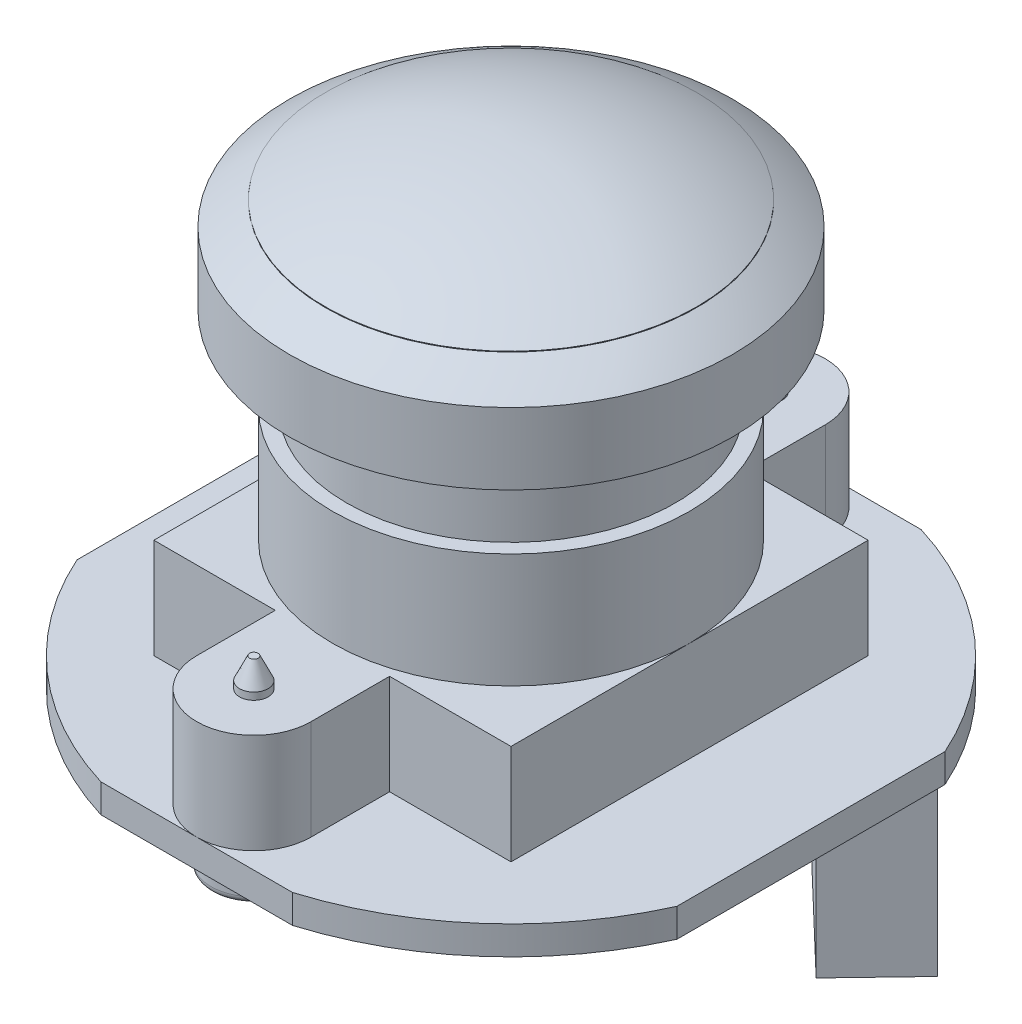
from build123d import *

# Parameters (mm, degrees)
BOSS_EXTRUDE1_DEPTH   = 1
BOSS_EXTRUDE2_DEPTH   = 6
SKETCH4_R             = 1.5
SKETCH4_W             = 6.5
SKETCH4_H             = 6.5
SKETCH4_W_2           = 3.913005348
SKETCH4_H_2           = 6.097566615
BOSS_EXTRUDE6_DEPTH   = 1
FILLET1_R             = 0.25
BOSS_EXTRUDE7_DEPTH   = 3.5
SKETCH6_R             = 6.25
BOSS_EXTRUDE8_DEPTH   = 4
SKETCH7_R             = 0.5
BOSS_EXTRUDE9_DEPTH   = 1
CHAMFER1_SIZE         = 0.75
CHAMFER1_SIZE2        = 0.349730744
CHAMFER1_PART_2_SIZE  = 0.75
CHAMFER1_PART_2_SIZE2 = 0.349730744


with BuildPart() as part:
    # Sketch1 → Boss-Extrude1 (new body)
    with BuildSketch(Plane(origin=(0, 0, 0), x_dir=(1, 0, 0), z_dir=(0, 1, 0))):
        with BuildLine():
            Line((-3.354101966, 11), (3.354101966, 11))
            ThreePointArc((3.354101966, 11), (7.611619318, 8.620513404), (10.5, 4.69041576))
            Line((10.5, 4.69041576), (10.5, -4.69041576))
            ThreePointArc((10.5, -4.69041576), (7.611619318, -8.620513404), (3.354101966, -11))
            Line((3.354101966, -11), (-3.354101966, -11))
            ThreePointArc((-3.354101966, -11), (-7.611619318, -8.620513404), (-10.5, -4.69041576))
            Line((-10.5, -4.69041576), (-10.5, 4.69041576))
            ThreePointArc((-10.5, 4.69041576), (-7.611619318, 8.620513404), (-3.354101966, 11))
        make_face()
    extrude(amount=BOSS_EXTRUDE1_DEPTH)

    # Sketch2 → Boss-Extrude2 (add)
    with BuildSketch(Plane.XZ):
        Polygon((8.109719748, -2.570195786), (10.184176938, -4.737366146), (4.405055978, -10.269251985), (2.330598788, -8.102081625), align=None)
    extrude(amount=BOSS_EXTRUDE2_DEPTH)

    # Sketch4 → Boss-Extrude6 (add)
    with BuildSketch(Plane.XZ):
        with Locations((0, -9)):
            Circle(SKETCH4_R)
        with Locations((0, 9)):
            Circle(SKETCH4_R)
        with Locations((1.885591241, -1.931388967)):
            Rectangle(SKETCH4_W, SKETCH4_H)
        Polygon((-6.789671936, 7.633587439), (-2.564617425, 4.781139469), (-5.233344576, 0.828212788), (-9.458399087, 3.680660758), align=None)
        with Locations((-6.013545028, -4.933267479)):
            Rectangle(SKETCH4_W_2, SKETCH4_H_2)
        with BuildLine():
            Line((7.537936682, 4.261094781), (8.522189561, 4.261094781))
            ThreePointArc((8.522189561, 4.261094781), (8.906288246, 3.876996096), (8.522189561, 3.492897412))
            Line((8.522189561, 3.492897412), (7.537936682, 3.492897412))
            ThreePointArc((7.537936682, 3.492897412), (7.153837998, 3.876996096), (7.537936682, 4.261094781))
        make_face()
        with BuildLine():
            Line((7.549939766, 3.276841902), (8.534192645, 3.276841902))
            ThreePointArc((8.534192645, 3.276841902), (8.918291329, 2.892743217), (8.534192645, 2.508644533))
            Line((8.534192645, 2.508644533), (7.549939766, 2.508644533))
            ThreePointArc((7.549939766, 2.508644533), (7.165841082, 2.892743217), (7.549939766, 3.276841902))
        make_face()
        with BuildLine():
            Line((7.393899676, 0.228058594), (8.378152554, 0.228058594))
            ThreePointArc((8.378152554, 0.228058594), (8.762251239, -0.156040091), (8.378152554, -0.540138775))
            Line((8.378152554, -0.540138775), (7.393899676, -0.540138775))
            ThreePointArc((7.393899676, -0.540138775), (7.009800991, -0.156040091), (7.393899676, 0.228058594))
        make_face()
        with BuildLine():
            Line((7.405902759, -0.756194285), (8.390155638, -0.756194285))
            ThreePointArc((8.390155638, -0.756194285), (8.774254323, -1.140292969), (8.390155638, -1.524391654))
            Line((8.390155638, -1.524391654), (7.405902759, -1.524391654))
            ThreePointArc((7.405902759, -1.524391654), (7.021804075, -1.140292969), (7.405902759, -0.756194285))
        make_face()
    extrude(amount=BOSS_EXTRUDE6_DEPTH)

    # Fillet1
    fillet1_edges = [part.edges().sort_by_distance(p)[0] for p in [
        (-1.5, -1, -9),
        (-1.5, -1, 9),
    ]]
    fillet(fillet1_edges, radius=FILLET1_R)

    # Sketch5 → Boss-Extrude7 (add)
    with BuildSketch(Plane(origin=(0, 1, 0), x_dir=(1, 0, 0), z_dir=(0, 1, 0))):
        with BuildLine():
            Line((-2, -6.25), (-2, -9))
            ThreePointArc((-2, -9), (0, -11), (2, -9))
            Line((2, -9), (2, -6.25))
            Line((2, -6.25), (6.25, -6.25))
            Line((6.25, -6.25), (6.25, 6.25))
            Line((6.25, 6.25), (2, 6.25))
            Line((2, 6.25), (2, 9))
            ThreePointArc((2, 9), (0, 11), (-2, 9))
            Line((-2, 9), (-2, 6.25))
            Line((-2, 6.25), (-6.25, 6.25))
            Line((-6.25, 6.25), (-6.25, -6.25))
            Line((-6.25, -6.25), (-2, -6.25))
        make_face()
    extrude(amount=BOSS_EXTRUDE7_DEPTH)

    # Sketch6 → Boss-Extrude8 (add)
    with BuildSketch(Plane(origin=(0, 4.5, 0), x_dir=(1, 0, 0), z_dir=(0, 1, 0))):
        Circle(SKETCH6_R)
    extrude(amount=BOSS_EXTRUDE8_DEPTH)

    # Sketch7 → Boss-Extrude9 (add)
    with BuildSketch(Plane(origin=(0, 4.5, 0), x_dir=(1, 0, 0), z_dir=(0, 1, 0))):
        with Locations((0, 9)):
            Circle(SKETCH7_R)
        with Locations((0, -9)):
            Circle(SKETCH7_R)
    extrude(amount=BOSS_EXTRUDE9_DEPTH)

    # Chamfer1
    chamfer1_edges = [part.edges().sort_by_distance(p)[0] for p in [
        (-0.5, 5.5, -9),
    ]]
    chamfer1_side = [part.faces().sort_by_distance(p)[0] for p in [
        (-0.5, 5, -9),
    ]]
    chamfer(chamfer1_edges, length=CHAMFER1_SIZE, length2=CHAMFER1_SIZE2, reference=chamfer1_side[0])

    # Chamfer1 part 2
    chamfer1_part_2_edges = [part.edges().sort_by_distance(p)[0] for p in [
        (-0.5, 5.5, 9),
    ]]
    chamfer1_part_2_side = [part.faces().sort_by_distance(p)[0] for p in [
        (-0.5, 5, 9),
    ]]
    chamfer(chamfer1_part_2_edges, length=CHAMFER1_PART_2_SIZE, length2=CHAMFER1_PART_2_SIZE2, reference=chamfer1_part_2_side[0])

    # Sketch8 → Revolve1 (revolve)
    with BuildSketch(Plane.XY):
        with BuildLine():
            Line((0, 4.5), (0, 16.5))
            Line((0, 16.5), (0, 16.525))
            ThreePointArc((0, 16.525), (3.359575443, 16.092432155), (6.5, 14.822945763))
            Line((6.5, 14.822945763), (6.5, 14.797945763))
            ThreePointArc((6.5, 14.797945763), (7.136161739, 14.416457997), (7.75, 14))
            Line((7.75, 14), (7.75, 11.5))
            Line((7.75, 11.5), (5.75, 11.5))
            Line((5.75, 11.5), (5.75, 4.5))
            Line((5.75, 4.5), (0, 4.5))
        make_face()
    revolve(axis=Axis((0, 4.5, 0), (0, 1, 0)))


solid = part.part
